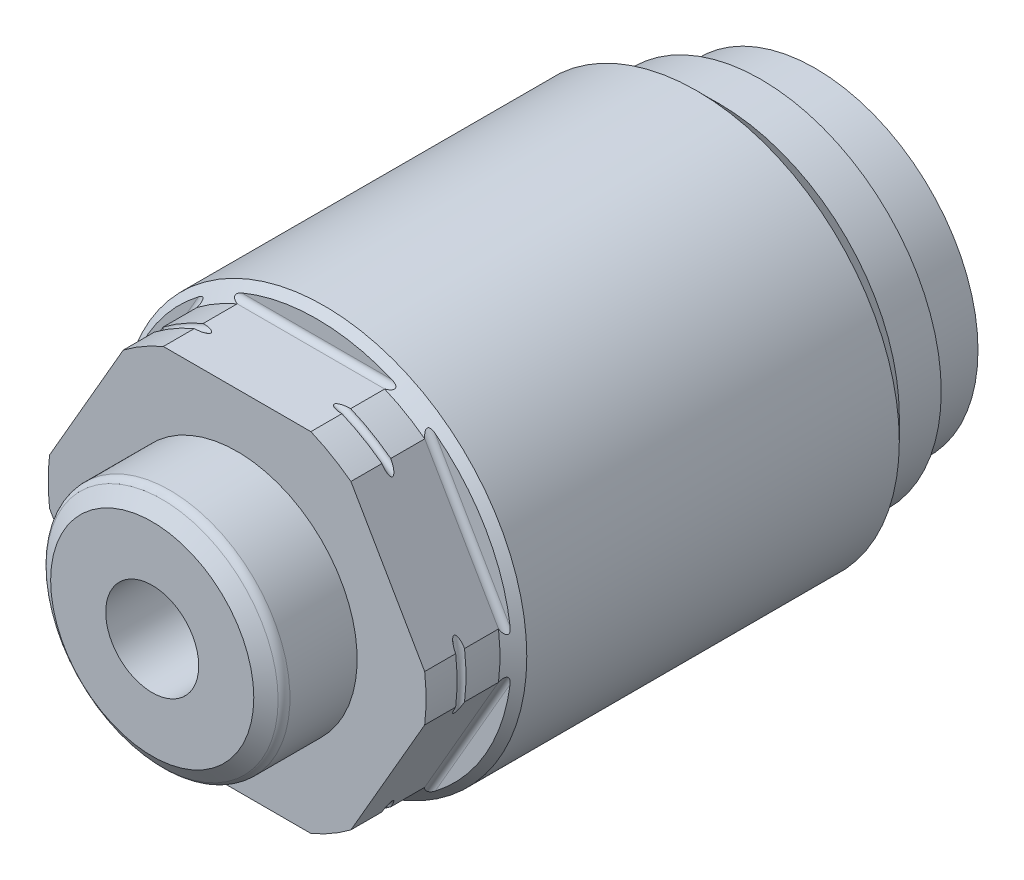
from build123d import *

# Parameters (mm, degrees)
CUT_EXTRUDE1_DEPTH = 18.4117
CIRPATTERN1_COUNT  = 6
SKETCH4_R          = 4.0005
CUT_EXTRUDE2_DEPTH = 6.0452


with BuildPart() as part:
    # Sketch1 → Revolve1 (revolve)
    with BuildSketch(Plane(origin=(0, 0, 0), x_dir=(0, 0, -1), z_dir=(1, 0, 0)), mode=Mode.PRIVATE) as revolve1_sk:
        Polygon((0, 0), (0, 13.9954), (-4.6736, 13.9954), (-4.6736, 15.5067), (-8.2804, 15.5067), (-10.1854, 17.4117), (-42.2275, 17.4117), (-43.3832, 16.256), (-49.7332, 16.256), (-49.7332, 0), align=None)
    revolve(revolve1_sk.sketch.rotate(Axis((0, 0, 0), (0, 0, -1)), 90), axis=Axis((0, 0, 0), (0, 0, -1)))  # turned: the seam where the file's is

    # Sketch2 → Cut-Extrude1 (cut, symmetric)
    with BuildSketch(Plane(origin=(0, 0, 0), x_dir=(0, 0, -1), z_dir=(1, 0, 0))):
        with BuildLine():
            Line((-49.7332, 14.96695), (-43.3832, 14.96695))
            ThreePointArc((-43.3832, 14.96695), (-43.023989755, 15.115739755), (-42.8752, 15.47495))
            Line((-42.8752, 15.47495), (-42.8752, 18.14195))
            Line((-42.8752, 18.14195), (-49.7332, 18.14195))
            Line((-49.7332, 18.14195), (-49.7332, 14.96695))
        make_face()
    cut_extrude1 = extrude(amount=CUT_EXTRUDE1_DEPTH, both=True, mode=Mode.SUBTRACT)

    # CirPattern1: Cut-Extrude1 ×6 about axis
    cirpattern1_axis = Axis((0, 0, 0), (0, 0, 1))
    for i in range(1, CIRPATTERN1_COUNT):
        add(cut_extrude1.rotate(cirpattern1_axis, i * 360 / CIRPATTERN1_COUNT), mode=Mode.SUBTRACT)

    # Sketch3 → Revolve2 (revolve)
    with BuildSketch(Plane(origin=(0, 0, 0), x_dir=(0, 0, -1), z_dir=(1, 0, 0)), mode=Mode.PRIVATE) as revolve2_sk:
        with BuildLine():
            Line((-57.0357, 0), (-57.0357, 8.7376))
            Line((-57.0357, 8.7376), (-56.180207199, 9.97462236))
            ThreePointArc((-56.180207199, 9.97462236), (-55.889104442, 10.232167854), (-55.5117, 10.3251))
            Line((-55.5117, 10.3251), (-49.7332, 10.3251))
            Line((-49.7332, 10.3251), (-49.7332, 0))
            Line((-49.7332, 0), (-57.0357, 0))
        make_face()
    revolve(revolve2_sk.sketch.rotate(Axis((0, 0, 0), (0, 0, 1)), 270), axis=Axis((0, 0, 0), (0, 0, 1)))  # turned: the seam where the file's is

    # Sketch4 → Cut-Extrude2 (cut)
    with BuildSketch(Plane.XY.offset(57.0357)):
        Circle(SKETCH4_R)
    extrude(amount=-CUT_EXTRUDE2_DEPTH, mode=Mode.SUBTRACT)

    # Sketch5 → Cut-Revolve1 (revolve, cut)
    with BuildSketch(Plane(origin=(0, 0, 0), x_dir=(0, 0, -1), z_dir=(1, 0, 0)), mode=Mode.PRIVATE) as cut_revolve1_sk:
        with BuildLine():
            Line((-47.0662, 19.431), (-47.0662, 16.256))
            ThreePointArc((-47.0662, 16.256), (-46.6852, 15.875), (-46.3042, 16.256))
            Line((-46.3042, 16.256), (-46.3042, 19.431))
            Line((-46.3042, 19.431), (-47.0662, 19.431))
        make_face()
    revolve(cut_revolve1_sk.sketch.rotate(Axis((0, 0, 0), (0, 0, 1)), 270), axis=Axis((0, 0, 0), (0, 0, 1)), mode=Mode.SUBTRACT)  # turned: the seam where the file's is


solid = part.part
